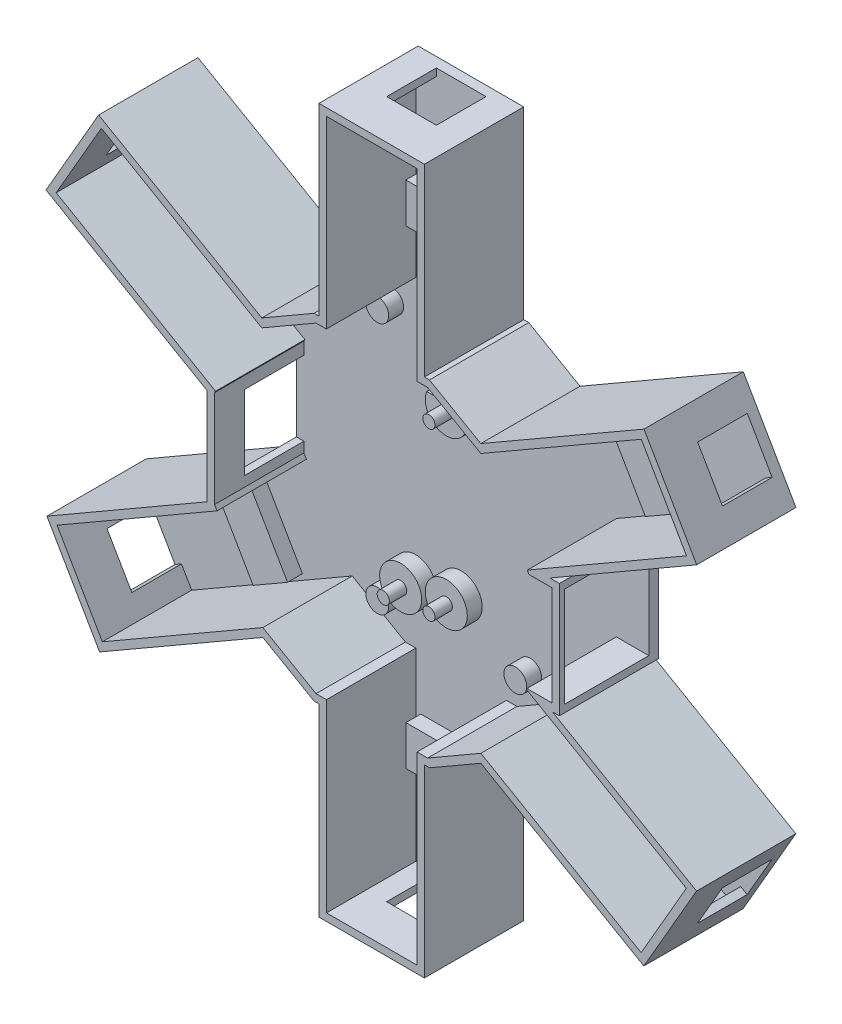
from build123d import *

# Parameters (mm, degrees)
AUFSATZ_LINEAR_AUSTRAGEN1_DEPTH = 18
AUFSATZ_LINEAR_AUSTRAGEN2_DEPTH = 2
SCHNITT_LINEAR_AUSTRAGEN1_REACH = 127.501
SCHNITT_LINEAR_AUSTRAGEN2_REACH = 123.638
SKIZZE5_W                       = 12
SKIZZE5_H                       = 15
SKIZZE7_R                       = 1.22999984
AUFSATZ_LINEAR_AUSTRAGEN3_DEPTH = 6.5
SKIZZE8_R                       = 4.22999984
SKIZZE8_R_2                     = 2.3
AUFSATZ_LINEAR_AUSTRAGEN4_DEPTH = 3
SKIZZE9_W                       = 16.252283896
SKIZZE9_H                       = 8
SKIZZE9_W_2                     = 16.225392475
AUFSATZ_LINEAR_AUSTRAGEN7_DEPTH = 3
SCHNITT_LINEAR_AUSTRAGEN3_REACH = 158.064
SKIZZE11_W                      = 10
SKIZZE11_H                      = 10
SCHNITT_LINEAR_AUSTRAGEN4_REACH = 167.245
SKIZZE13_W                      = 10
SKIZZE13_H                      = 10
SCHNITT_LINEAR_AUSTRAGEN5_REACH = 167.158
SKIZZE14_W                      = 10
SKIZZE14_H                      = 10
SCHNITT_LINEAR_AUSTRAGEN6_REACH = 158.064
SKIZZE15_W                      = 10
SKIZZE15_H                      = 10
SCHNITT_LINEAR_AUSTRAGEN7_REACH = 167.062
SKIZZE16_W                      = 10
SKIZZE16_H                      = 10
SCHNITT_LINEAR_AUSTRAGEN8_REACH = 167.189
SKIZZE17_W                      = 10
SKIZZE17_H                      = 10


with BuildPart() as part:
    # Skizze1 → Aufsatz-Linear austragen1 (new body)
    with BuildSketch(Plane.XY):
        Polygon((-22.149859894, 27.765281808), (-11.635793215, 33.83000044), (-10.65000108, 33.83000044), (-10.65000108, 70.94999986), (10.5900012, 70.94999986), (10.5900012, 33.83000044), (11.612735063, 33.83000044), (21.946878227, 27.90320319), (54.822266278, 46.860690996), (65.431940836, 28.488460753), (35.875483821, 11.41999954), (37.79000014, 11.41999954), (37.79000014, -11.66999904), (36.372671479, -11.66999904), (65.402118422, -28.428154068), (54.791716349, -46.801638497), (21.961456264, -27.849347945), (11.636228403, -33.81000048), (10.608764603, -33.81000048), (10.588764643, -70.99999976), (-10.63000112, -70.99999976), (-10.63000112, -33.81000048), (-11.635211495, -33.81000048), (-21.94526311, -27.869445957), (-54.832668225, -46.841377939), (-65.441180026, -28.458395245), (-33.1799992, -9.82193495), (-33.1799992, 9.582671858), (-65.619428736, 28.349034811), (-55.023633975, 46.732102334), align=None)
        Polygon((-22.149950537, 26.033576659), (-11.234189479, 32.33000044), (-9.15000108, 32.33000044), (-9.15000108, 69.44999986), (9.0900012, 69.44999986), (9.0900012, 32.33000044), (11.2131258, 32.33000044), (21.948913697, 26.172853479), (54.272963006, 44.812413555), (63.382848908, 29.03729054), (31.311020441, 10.516235735), (31.653238716, 9.91999954), (36.29000014, 9.91999954), (36.29000014, -10.16999904), (31.252050971, -10.16999904), (31.132619329, -10.37701429), (63.352910716, -28.977183946), (54.242770108, -44.752743199), (21.961450411, -26.11734559), (11.234340849, -32.31000048), (9.109571053, -32.31000048), (9.089571093, -69.49999976), (-9.13000112, -69.49999976), (-9.13000112, -32.31000048), (-11.233987142, -32.31000048), (-21.945708018, -26.138007916), (-54.2831028, -44.792652518), (-63.392584266, -29.007267794), (-31.162137007, -10.388561496), (-31.6799992, -9.546253935), (-31.6799992, 9.963511331), (-31.471105622, 10.326986156), (-63.571974887, 28.897490395), (-54.473438465, 44.682904625), align=None, mode=Mode.SUBTRACT)
    extrude(amount=AUFSATZ_LINEAR_AUSTRAGEN1_DEPTH)

    # Skizze3 → Aufsatz-Linear austragen2 (add)
    with BuildSketch(Plane(origin=(0, 0, 0), x_dir=(-1, 0, 0), z_dir=(0, 0, -1))):
        Polygon((55.023633975, 46.732102334), (22.149859894, 27.765281808), (11.635793215, 33.83000044), (10.65000108, 33.83000044), (10.65000108, 70.94999986), (-10.5900012, 70.94999986), (-10.5900012, 33.83000044), (-11.612735063, 33.83000044), (-21.946878227, 27.90320319), (-54.822266278, 46.860690996), (-65.431940836, 28.488460753), (-35.875483821, 11.41999954), (-37.79000014, 11.41999954), (-37.79000014, -11.66999904), (-36.372671479, -11.66999904), (-65.402118422, -28.428154068), (-54.791716349, -46.801638497), (-21.961456264, -27.849347945), (-11.636228403, -33.81000048), (-10.608764603, -33.81000048), (-10.588764643, -70.99999976), (10.63000112, -70.99999976), (10.63000112, -33.81000048), (11.635211495, -33.81000048), (21.94526311, -27.869445957), (54.832668225, -46.841377939), (65.441180026, -28.458395245), (33.1799992, -9.82193495), (33.1799992, 9.582671858), (65.619428736, 28.349034811), align=None)
    extrude(amount=AUFSATZ_LINEAR_AUSTRAGEN2_DEPTH)

    # Skizze4 → Schnitt-Linear austragen1 (cut, up to next)
    with BuildSketch(Plane.ZY.offset(-36.29000014), mode=Mode.PRIVATE) as schnitt_linear_austragen1_sk1:
        Polygon((17.00382914, 9.91999954), (17.00382914, -10.16999904), (0.851260669, -10.16999904), (0, -10.16999904), (0, 9.91999954), (0.851260669, 9.91999954), align=None)
    schnitt_linear_austragen1_tool1 = extrude(schnitt_linear_austragen1_sk1.sketch, amount=-SCHNITT_LINEAR_AUSTRAGEN1_REACH, mode=Mode.PRIVATE) & part.part
    add(schnitt_linear_austragen1_tool1.solids().sort_by_distance((36.29, -0.125, 8.501915))[0], mode=Mode.SUBTRACT)

    # Skizze5 → Schnitt-Linear austragen2 (cut, up to next)
    with BuildSketch(Plane(origin=(-31.6799992, 0, 0), x_dir=(0, 0, -1), z_dir=(1, 0, 0)), mode=Mode.PRIVATE) as schnitt_linear_austragen2_sk1:
        with Locations((-6, 0)):
            Rectangle(SKIZZE5_W, SKIZZE5_H)
    schnitt_linear_austragen2_tool1 = extrude(schnitt_linear_austragen2_sk1.sketch, amount=-SCHNITT_LINEAR_AUSTRAGEN2_REACH, mode=Mode.PRIVATE) & part.part
    add(schnitt_linear_austragen2_tool1.solids().sort_by_distance((-31.679999, 0, 6))[0], mode=Mode.SUBTRACT)

    # Skizze7 → Aufsatz-Linear austragen3 (add)
    with BuildSketch(Plane.XY):
        with Locations((0, 15.00000048)):
            Circle(SKIZZE7_R)
        with Locations((0, -18.5000011)):
            Circle(SKIZZE7_R)
        with Locations((-9.1899994, -20.2700001)):
            Circle(SKIZZE7_R)
    extrude(amount=AUFSATZ_LINEAR_AUSTRAGEN3_DEPTH)

    # Skizze8 → Aufsatz-Linear austragen4 (add)
    with BuildSketch(Plane.XY):
        with Locations((-9.1899994, -20.2700001)):
            Circle(SKIZZE8_R)
        with Locations((0, -18.5000011)):
            Circle(SKIZZE8_R)
        with Locations((13.9, 25.897140228)):
            Circle(SKIZZE8_R_2)
        with Locations((-13.9, 25.897140228)):
            Circle(SKIZZE8_R_2)
        with Locations((13.9, -24.8615628)):
            Circle(SKIZZE8_R_2)
        with Locations((-13.9, -24.8615628)):
            Circle(SKIZZE8_R_2)
        with BuildLine():
            Line((3.936452455, 16.548303007), (-3.936452455, 16.548303007))
            ThreePointArc((-3.936452455, 16.548303007), (0, 10.77000064), (3.936452455, 16.548303007))
        make_face()
    extrude(amount=AUFSATZ_LINEAR_AUSTRAGEN4_DEPTH)

    # Skizze9 → Aufsatz-Linear austragen7 (add)
    with BuildSketch(Plane.XY):
        Polygon((-39.106966425, 34.662574989), (-47.255864546, 20.538698219), (-40.326487672, 16.540731718), (-32.177589551, 30.664608488), align=None)
        with Locations((-0.036140748, 47.33000044)):
            Rectangle(SKIZZE9_W, SKIZZE9_H)
        Polygon((40.096213315, 16.744336658), (31.986065924, 30.788205039), (38.913859811, 34.78891396), (47.024007202, 20.745045579), align=None)
        Polygon((40.10078632, -16.697308213), (47.029196881, -20.696949084), (38.916380603, -34.750441337), (31.987970041, -30.750800466), align=None)
        with Locations((-0.017304883, -47.31000048)):
            Rectangle(SKIZZE9_W_2, SKIZZE9_H)
        Polygon((-38.906027405, -34.762365837), (-31.978796823, -30.760681634), (-40.098111463, -16.705508406), (-47.025342045, -20.70719261), align=None)
    extrude(amount=AUFSATZ_LINEAR_AUSTRAGEN7_DEPTH)

    # Skizze11 → Schnitt-Linear austragen3 (cut, up to next)
    with BuildSketch(Plane.XZ.offset(-69.44999986), mode=Mode.PRIVATE) as schnitt_linear_austragen3_sk1:
        with Locations((0, 5)):
            Rectangle(SKIZZE11_W, SKIZZE11_H)
    schnitt_linear_austragen3_tool1 = extrude(schnitt_linear_austragen3_sk1.sketch, amount=-SCHNITT_LINEAR_AUSTRAGEN3_REACH, mode=Mode.PRIVATE) & part.part
    add(schnitt_linear_austragen3_tool1.solids().sort_by_distance((0, 69.45, 5))[0], mode=Mode.SUBTRACT)

    # Skizze13 → Schnitt-Linear austragen4 (cut, up to next)
    with BuildSketch(Plane(origin=(60.106593545, 34.710614216, 0), x_dir=(0, 0, 1), z_dir=(-0.8659751400407392, -0.5000870492538497, 0)), mode=Mode.PRIVATE) as schnitt_linear_austragen4_sk1:
        with Locations((5, 2.556930019)):
            Rectangle(SKIZZE13_W, SKIZZE13_H)
    schnitt_linear_austragen4_tool1 = extrude(schnitt_linear_austragen4_sk1.sketch, amount=-SCHNITT_LINEAR_AUSTRAGEN4_REACH, mode=Mode.PRIVATE) & part.part
    add(schnitt_linear_austragen4_tool1.solids().sort_by_distance((58.827906, 36.924852, 5))[0], mode=Mode.SUBTRACT)

    # Skizze14 → Schnitt-Linear austragen5 (cut, up to next)
    with BuildSketch(Plane(origin=(60.058107222, -34.682624727, 0), x_dir=(0, 0, 1), z_dir=(-0.8659750738448291, 0.5000871638819006, 0)), mode=Mode.PRIVATE) as schnitt_linear_austragen5_sk1:
        with Locations((5, -2.520094297)):
            Rectangle(SKIZZE14_W, SKIZZE14_H)
    schnitt_linear_austragen5_tool1 = extrude(schnitt_linear_austragen5_sk1.sketch, amount=-SCHNITT_LINEAR_AUSTRAGEN5_REACH, mode=Mode.PRIVATE) & part.part
    add(schnitt_linear_austragen5_tool1.solids().sort_by_distance((58.79784, -36.864964, 5))[0], mode=Mode.SUBTRACT)

    # Skizze15 → Schnitt-Linear austragen6 (cut, up to next)
    with BuildSketch(Plane(origin=(0, -69.49999976, 0), x_dir=(1, 0, 0), z_dir=(0, 1, 0)), mode=Mode.PRIVATE) as schnitt_linear_austragen6_sk1:
        with Locations((-0.020215013, -5)):
            Rectangle(SKIZZE15_W, SKIZZE15_H)
    schnitt_linear_austragen6_tool1 = extrude(schnitt_linear_austragen6_sk1.sketch, amount=-SCHNITT_LINEAR_AUSTRAGEN6_REACH, mode=Mode.PRIVATE) & part.part
    add(schnitt_linear_austragen6_tool1.solids().sort_by_distance((-0.020215, -69.5, 5))[0], mode=Mode.SUBTRACT)

    # Skizze16 → Schnitt-Linear austragen7 (cut, up to next)
    with BuildSketch(Plane(origin=(-60.113041463, -34.690230655, 0), x_dir=(0, 0, -1), z_dir=(0.8661255219511101, 0.49982655014006316, 0)), mode=Mode.PRIVATE) as schnitt_linear_austragen7_sk1:
        with Locations((-5, -2.551280899)):
            Rectangle(SKIZZE16_W, SKIZZE16_H)
    schnitt_linear_austragen7_tool1 = extrude(schnitt_linear_austragen7_sk1.sketch, amount=-SCHNITT_LINEAR_AUSTRAGEN7_REACH, mode=Mode.PRIVATE) & part.part
    add(schnitt_linear_austragen7_tool1.solids().sort_by_distance((-58.837844, -36.89996, 5))[0], mode=Mode.SUBTRACT)

    # Skizze17 → Schnitt-Linear austragen8 (cut, up to next)
    with BuildSketch(Plane(origin=(-60.221224503, 34.710841064, 0), x_dir=(0, 0, -1), z_dir=(0.8663858686371327, -0.4993751361710765, 0)), mode=Mode.PRIVATE) as schnitt_linear_austragen8_sk1:
        with Locations((-5, 2.400035044)):
            Rectangle(SKIZZE17_W, SKIZZE17_H)
    schnitt_linear_austragen8_tool1 = extrude(schnitt_linear_austragen8_sk1.sketch, amount=-SCHNITT_LINEAR_AUSTRAGEN8_REACH, mode=Mode.PRIVATE) & part.part
    add(schnitt_linear_austragen8_tool1.solids().sort_by_distance((-59.022707, 36.790198, 5))[0], mode=Mode.SUBTRACT)


solid = part.part
